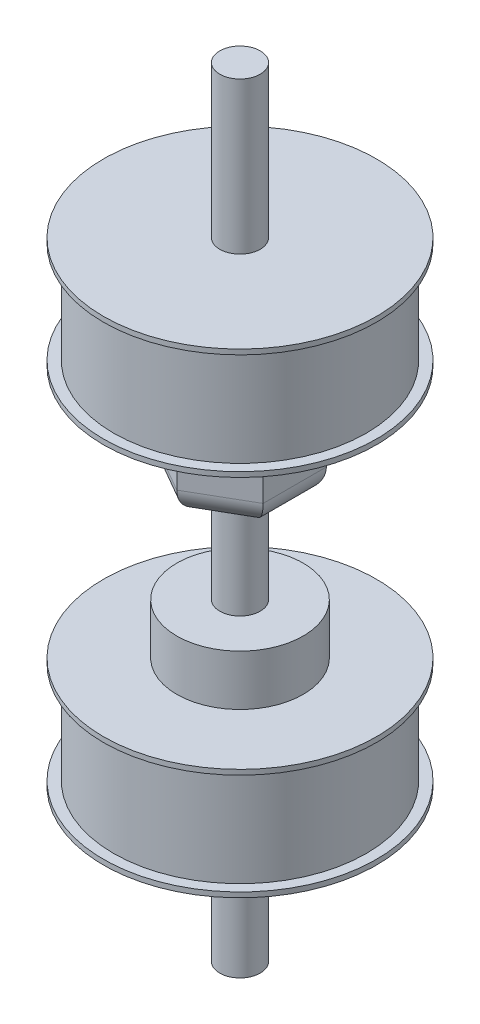
from build123d import *

# Parameters (mm, degrees)
SKETCH2_R            = 27
BOSS_EXTRUDE1_DEPTH  = 1
SKETCH3_R            = 12.5
BOSS_EXTRUDE2_DEPTH  = 10
SKETCH4_R            = 4
BOSS_EXTRUDE3_DEPTH  = 20
BOSS_EXTRUDE4_DEPTH  = 20
FILLET1_R            = 5
SKETCH6_R            = 27
BOSS_EXTRUDE5_DEPTH  = 1
SKETCH7_R            = 25
BOSS_EXTRUDE6_DEPTH  = 20
SKETCH8_R            = 27
BOSS_EXTRUDE7_DEPTH  = 1
SKETCH9_R            = 4
BOSS_EXTRUDE8_DEPTH  = 30
SKETCH10_R           = 25
BOSS_EXTRUDE9_DEPTH  = 20
SKETCH11_R           = 27
BOSS_EXTRUDE10_DEPTH = 1
SKETCH12_R           = 4
BOSS_EXTRUDE11_DEPTH = 30


with BuildPart() as part:
    # Sketch2 → Boss-Extrude1 (new body)
    with BuildSketch(Plane(origin=(0, 0, 0), x_dir=(1, 0, 0), z_dir=(0, 1, 0))):
        Circle(SKETCH2_R)
    extrude(amount=BOSS_EXTRUDE1_DEPTH)

    # Sketch3 → Boss-Extrude2 (add)
    with BuildSketch(Plane(origin=(0, 1, 0), x_dir=(1, 0, 0), z_dir=(0, 1, 0))):
        Circle(SKETCH3_R)
    extrude(amount=BOSS_EXTRUDE2_DEPTH)

    # Sketch4 → Boss-Extrude3 (add)
    with BuildSketch(Plane(origin=(0, 11, 0), x_dir=(1, 0, 0), z_dir=(0, 1, 0))):
        Circle(SKETCH4_R)
    extrude(amount=BOSS_EXTRUDE3_DEPTH)

    # Sketch5 → Boss-Extrude4 (add)
    with BuildSketch(Plane(origin=(0, 31, 0), x_dir=(1, 0, 0), z_dir=(0, 1, 0))):
        Polygon((0, 12.5), (10.825317547, 6.25), (10.825317547, -6.25), (0, -12.5), (-10.825317547, -6.25), (-10.825317547, 6.25), align=None)
    extrude(amount=BOSS_EXTRUDE4_DEPTH)

    # Fillet1
    fillet1_edges = [part.edges().sort_by_distance(p)[0] for p in [
        (-5.412658774, 31, -9.375),
        (-10.825317547, 31, 0),
        (-5.412658774, 31, 9.375),
        (5.412658774, 31, 9.375),
        (10.825317547, 31, 0),
        (5.412658774, 31, -9.375),
    ]]
    fillet(fillet1_edges, radius=FILLET1_R)

    # Sketch6 → Boss-Extrude5 (add)
    with BuildSketch(Plane(origin=(0, 51, 0), x_dir=(1, 0, 0), z_dir=(0, 1, 0))):
        Circle(SKETCH6_R)
    extrude(amount=BOSS_EXTRUDE5_DEPTH)

    # Sketch7 → Boss-Extrude6 (add)
    with BuildSketch(Plane(origin=(0, 52, 0), x_dir=(1, 0, 0), z_dir=(0, 1, 0))):
        Circle(SKETCH7_R)
    extrude(amount=BOSS_EXTRUDE6_DEPTH)

    # Sketch8 → Boss-Extrude7 (add)
    with BuildSketch(Plane(origin=(0, 72, 0), x_dir=(1, 0, 0), z_dir=(0, 1, 0))):
        Circle(SKETCH8_R)
    extrude(amount=BOSS_EXTRUDE7_DEPTH)

    # Sketch9 → Boss-Extrude8 (add)
    with BuildSketch(Plane(origin=(0, 73, 0), x_dir=(1, 0, 0), z_dir=(0, 1, 0))):
        Circle(SKETCH9_R)
    extrude(amount=BOSS_EXTRUDE8_DEPTH)

    # Sketch10 → Boss-Extrude9 (add)
    with BuildSketch(Plane(origin=(0, 0, 0), x_dir=(-1, 0, 0), z_dir=(0, -1, 0))):
        Circle(SKETCH10_R)
    extrude(amount=BOSS_EXTRUDE9_DEPTH)

    # Sketch11 → Boss-Extrude10 (add)
    with BuildSketch(Plane(origin=(0, -20, 0), x_dir=(-1, 0, 0), z_dir=(0, -1, 0))):
        Circle(SKETCH11_R)
    extrude(amount=BOSS_EXTRUDE10_DEPTH)

    # Sketch12 → Boss-Extrude11 (add)
    with BuildSketch(Plane(origin=(0, -21, 0), x_dir=(-1, 0, 0), z_dir=(0, -1, 0))):
        Circle(SKETCH12_R)
    extrude(amount=BOSS_EXTRUDE11_DEPTH)


solid = part.part
